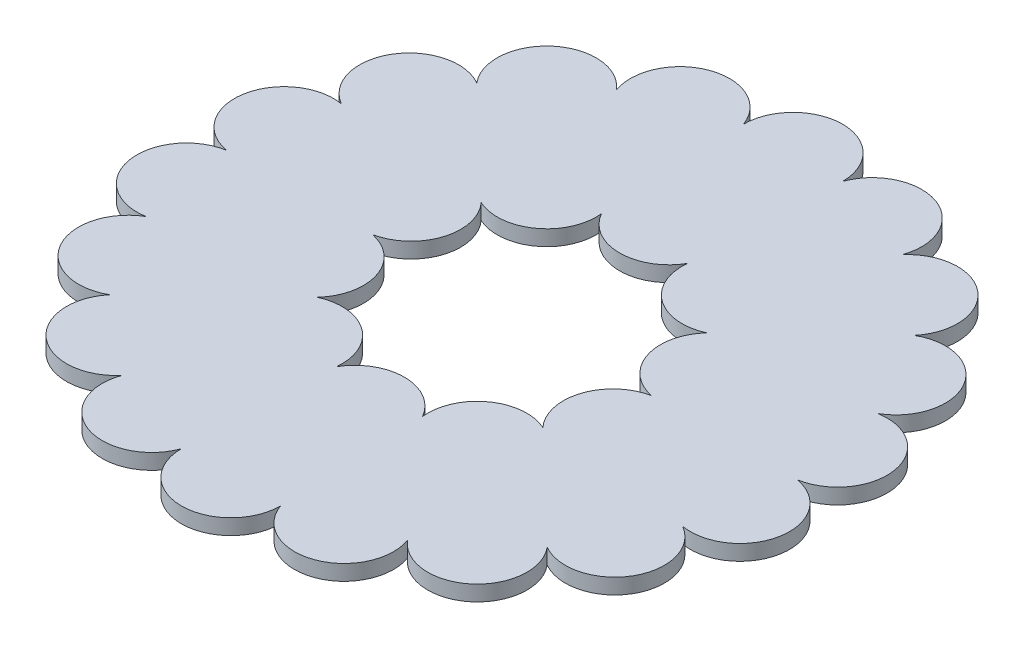
from build123d import *

# Parameters (mm, degrees)
SKETCH1_R           = 115.202561211
SKETCH1_R_2         = 64.402561211
BOSS_EXTRUDE1_DEPTH = 6.35
SKETCH2_R           = 20.32
BOSS_EXTRUDE2_DEPTH = 6.35


with BuildPart() as part:
    # Sketch1 → Boss-Extrude1 (new body)
    with BuildSketch(Plane(origin=(0, 0, 0), x_dir=(1, 0, 0), z_dir=(0, 1, 0))):
        Circle(SKETCH1_R)
        Circle(SKETCH1_R_2, mode=Mode.SUBTRACT)
    extrude(amount=BOSS_EXTRUDE1_DEPTH)

    # Sketch2 → Boss-Extrude2 (add)
    with BuildSketch(Plane(origin=(0, 6.35, 0), x_dir=(1, 0, 0), z_dir=(0, 1, 0))):
        with Locations((0, 64.402561211)):
            Circle(SKETCH2_R)
        with Locations((0, 115.202561211)):
            Circle(SKETCH2_R)
        with Locations((37.85487569, 52.102766501)):
            Circle(SKETCH2_R)
        with Locations((61.250475506, 19.901485895)):
            Circle(SKETCH2_R)
        with Locations((61.250475506, -19.901485895)):
            Circle(SKETCH2_R)
        with Locations((37.85487569, -52.102766501)):
            Circle(SKETCH2_R)
        with Locations((0, -64.402561211)):
            Circle(SKETCH2_R)
        with Locations((-37.85487569, -52.102766501)):
            Circle(SKETCH2_R)
        with Locations((-61.250475506, -19.901485895)):
            Circle(SKETCH2_R)
        with Locations((-61.250475506, 19.901485895)):
            Circle(SKETCH2_R)
        with Locations((-37.85487569, 52.102766501)):
            Circle(SKETCH2_R)
        with Locations((39.401596497, 108.254996665)):
            Circle(SKETCH2_R)
        with Locations((74.05077895, 88.250281849)):
            Circle(SKETCH2_R)
        with Locations((99.768344589, 57.601280605)):
            Circle(SKETCH2_R)
        with Locations((113.452375447, 20.004714817)):
            Circle(SKETCH2_R)
        with Locations((113.452375447, -20.004714817)):
            Circle(SKETCH2_R)
        with Locations((99.76834459, -57.601280605)):
            Circle(SKETCH2_R)
        with Locations((74.05077895, -88.250281849)):
            Circle(SKETCH2_R)
        with Locations((39.401596497, -108.254996665)):
            Circle(SKETCH2_R)
        with Locations((0, -115.202561211)):
            Circle(SKETCH2_R)
        with Locations((-39.401596497, -108.254996665)):
            Circle(SKETCH2_R)
        with Locations((-74.05077895, -88.250281849)):
            Circle(SKETCH2_R)
        with Locations((-99.768344589, -57.601280605)):
            Circle(SKETCH2_R)
        with Locations((-113.452375447, -20.004714817)):
            Circle(SKETCH2_R)
        with Locations((-113.452375447, 20.004714817)):
            Circle(SKETCH2_R)
        with Locations((-99.768344589, 57.601280605)):
            Circle(SKETCH2_R)
        with Locations((-74.05077895, 88.250281849)):
            Circle(SKETCH2_R)
        with Locations((-39.401596497, 108.254996665)):
            Circle(SKETCH2_R)
    extrude(amount=-BOSS_EXTRUDE2_DEPTH)


solid = part.part
